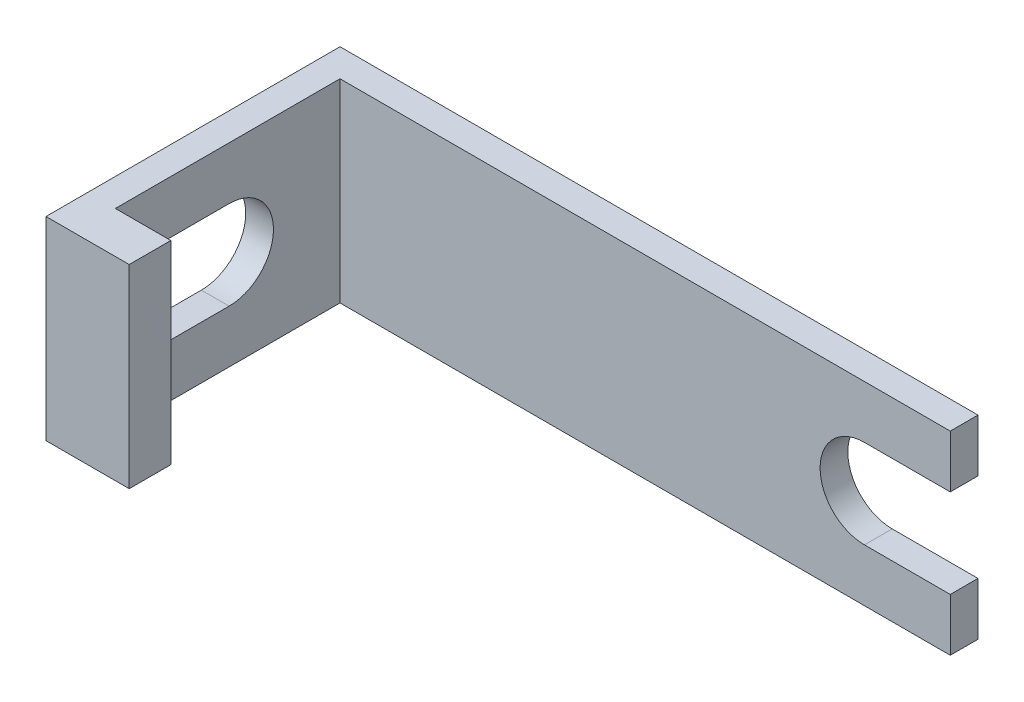
from build123d import *

# Parameters (mm, degrees)
DODANIE_WYCI_GNI_CIE1_DEPTH = 1
SZKIC12_W                   = 9.1
SZKIC12_H                   = 7
DODANIE_WYCI_GNI_CIE2_DEPTH = 1
SZKIC15_W                   = 1.5
SZKIC15_H                   = 7
DODANIE_WYCI_GNI_CIE3_DEPTH = 3
WYTNIJ_WYCI_GNI_CIE1_DEPTH  = 1


with BuildPart() as part:
    # Szkic1 → Dodanie-wyciągnięcie1 (new body)
    with BuildSketch(Plane.XY):
        with BuildLine():
            Line((-7.206635208, 4.522640333), (-7.206635208, -2.477359667))
            Line((-7.206635208, -2.477359667), (15.793364792, -2.477359667))
            Line((15.793364792, -2.477359667), (15.793364792, -0.577359667))
            Line((15.793364792, -0.577359667), (13.620412834, -0.577359667))
            Line((13.620412834, -0.577359667), (12.700412834, -0.577359667))
            ThreePointArc((12.700412834, -0.577359667), (11.100412834, 1.022640333), (12.700412834, 2.622640333))
            Line((12.700412834, 2.622640333), (13.620412834, 2.622640333))
            Line((13.620412834, 2.622640333), (15.793364792, 2.622640333))
            Line((15.793364792, 2.622640333), (15.793364792, 4.522640333))
            Line((15.793364792, 4.522640333), (-7.206635208, 4.522640333))
        make_face()
    extrude(amount=DODANIE_WYCI_GNI_CIE1_DEPTH)

    # Szkic12 → Dodanie-wyciągnięcie2 (add)
    with BuildSketch(Plane.ZY.offset(7.206635208)):
        with Locations((4.55, 1.022640333)):
            Rectangle(SZKIC12_W, SZKIC12_H)
    extrude(amount=-DODANIE_WYCI_GNI_CIE2_DEPTH)

    # Szkic15 → Dodanie-wyciągnięcie3 (add)
    with BuildSketch(Plane.ZY.offset(7.206635208)):
        with Locations((9.85, 1.022640333)):
            Rectangle(SZKIC15_W, SZKIC15_H)
    extrude(amount=-DODANIE_WYCI_GNI_CIE3_DEPTH)

    # Szkic16 → Wytnij-wyciągnięcie1 (cut)
    with BuildSketch(Plane(origin=(-6.206635208, 0, 0), x_dir=(0, 0, -1), z_dir=(1, 0, 0))):
        with BuildLine():
            Line((-7.5, -0.577359667), (-5, -0.577359667))
            ThreePointArc((-5, -0.577359667), (-3.4, 1.022640333), (-5, 2.622640333))
            Line((-5, 2.622640333), (-7.5, 2.622640333))
            ThreePointArc((-7.5, 2.622640333), (-9.1, 1.022640333), (-7.5, -0.577359667))
        make_face()
    extrude(amount=-WYTNIJ_WYCI_GNI_CIE1_DEPTH, mode=Mode.SUBTRACT)


solid = part.part
